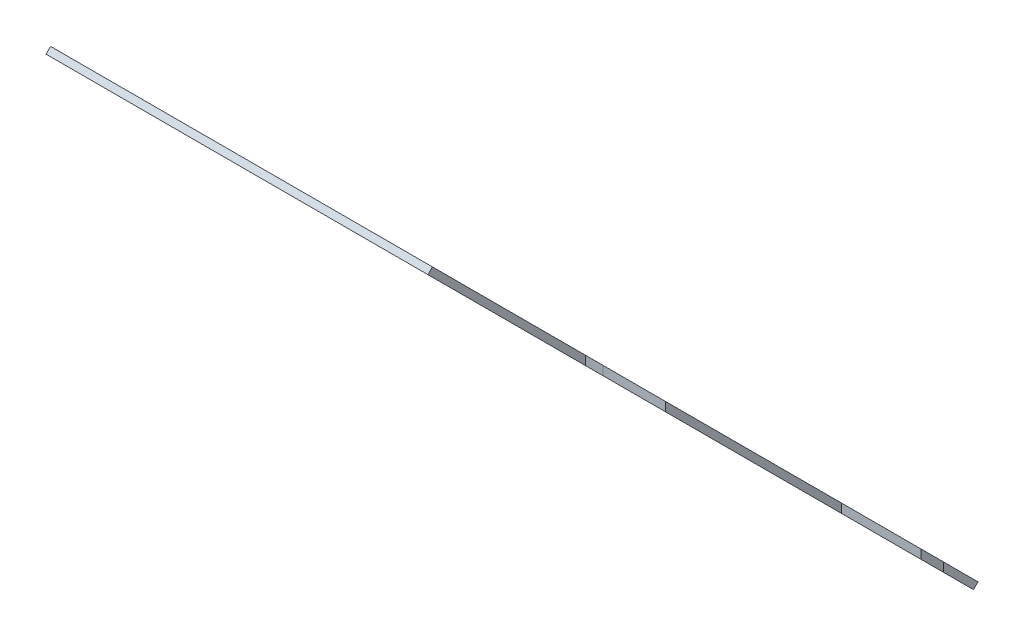
from build123d import *

# Parameters (mm, degrees)
BOSS_EXTRUDE1_START = -22799.561142
BOSS_EXTRUDE1_DEPTH = 600
CUT_EXTRUDE1_START  = 2846.116519
CUT_EXTRUDE1_DEPTH  = 541.072944
BOSS_EXTRUDE2_DEPTH = 498
CUT_EXTRUDE2_DEPTH  = 689.125788175


with BuildPart() as part:
    # Sketch3 → Boss-Extrude1 (new body)
    with BuildSketch(Plane(origin=(0, 0, 0), x_dir=(0, 0, -1), z_dir=(1, 0, 0)).offset(BOSS_EXTRUDE1_START)):
        Polygon((-40199.900195068, 2810.990103756), (-41009.724035702, 3620.813944389), (-41002.65296789, 3627.885012201), (-40199.900195068, 2825.132239379), align=None)
    extrude(amount=-BOSS_EXTRUDE1_DEPTH)

    # Sketch4 → Cut-Extrude1 (cut)
    with BuildSketch(Plane(origin=(0, 0, 0), x_dir=(1, 0, 0), z_dir=(0, 1, 0)).offset(CUT_EXTRUDE1_START)):
        with BuildLine():
            Line((-22799.561141737, -40360.17380628), (-23030.548097876, -40360.17380628))
            ThreePointArc((-23030.548097876, -40360.17380628), (-23093.121695819, -40297.600208337), (-23030.548097876, -40235.026610394))
            Line((-23030.548097876, -40235.026610394), (-22799.561141737, -40235.026610394))
            Line((-22799.561141737, -40235.026610394), (-22799.561141737, -40360.17380628))
        make_face()
        with BuildLine():
            Line((-22799.561141728, -40761.957418224), (-22897.41060103, -40761.957418224))
            ThreePointArc((-22897.41060103, -40761.957418224), (-22959.984198973, -40699.383820281), (-22897.41060103, -40636.810222338))
            Line((-22897.41060103, -40636.810222338), (-22799.561141728, -40636.810222338))
            Line((-22799.561141728, -40636.810222338), (-22799.561141728, -40761.957418224))
        make_face()
    extrude(amount=CUT_EXTRUDE1_DEPTH, mode=Mode.SUBTRACT)

    # Sketch5 → Boss-Extrude2 (add)
    with BuildSketch(Plane.ZY.offset(23399.561141728)):
        Polygon((40050.70934907, 2661.799257758), (40199.900195068, 2810.990103756), (40199.900195068, 2825.132239379), (40043.638281258, 2668.870325569), align=None)
    extrude(amount=-BOSS_EXTRUDE2_DEPTH)

    # Sketch6 → Cut-Extrude2 (cut, through all)
    with BuildSketch(Plane(origin=(0, -18687.383977844, 18687.383977844), x_dir=(1, 0, 0), z_dir=(0, 0.707106781, -0.707106781))):
        with BuildLine():
            Line((-23349.561141728, -30426.804477376), (-23164.561141728, -30426.804477376))
            ThreePointArc((-23164.561141728, -30426.804477376), (-23154.561141728, -30416.804477376), (-23164.561141728, -30406.804477376))
            Line((-23164.561141728, -30406.804477376), (-23359.561141728, -30406.804477376))
            ThreePointArc((-23359.561141728, -30406.804477376), (-23366.63220954, -30409.733409565), (-23369.561141728, -30416.804477376))
            Line((-23369.561141728, -30416.804477376), (-23369.561141728, -31160.804477376))
            ThreePointArc((-23369.561141728, -31160.804477376), (-23366.63220954, -31167.875545188), (-23359.561141728, -31170.804477376))
            Line((-23359.561141728, -31170.804477376), (-23039.561141728, -31170.804477376))
            ThreePointArc((-23039.561141728, -31170.804477376), (-23029.561141728, -31160.804477376), (-23039.561141728, -31150.804477376))
            Line((-23039.561141728, -31150.804477376), (-23349.561141728, -31150.804477376))
            Line((-23349.561141728, -31150.804477376), (-23349.561141728, -30990.804477376))
            Line((-23349.561141728, -30990.804477376), (-23039.561141728, -30990.804477376))
            ThreePointArc((-23039.561141728, -30990.804477376), (-23029.561141728, -30980.804477376), (-23039.561141728, -30970.804477376))
            Line((-23039.561141728, -30970.804477376), (-23349.561141728, -30970.804477376))
            Line((-23349.561141728, -30970.804477376), (-23349.561141728, -30606.804477376))
            Line((-23349.561141728, -30606.804477376), (-23164.561141728, -30606.804477376))
            ThreePointArc((-23164.561141728, -30606.804477376), (-23154.561141728, -30596.804477376), (-23164.561141728, -30586.804477376))
            Line((-23164.561141728, -30586.804477376), (-23349.561141728, -30586.804477376))
            Line((-23349.561141728, -30586.804477376), (-23349.561141728, -30426.804477376))
        make_face()
    extrude(amount=-CUT_EXTRUDE2_DEPTH, mode=Mode.SUBTRACT)


solid = part.part
